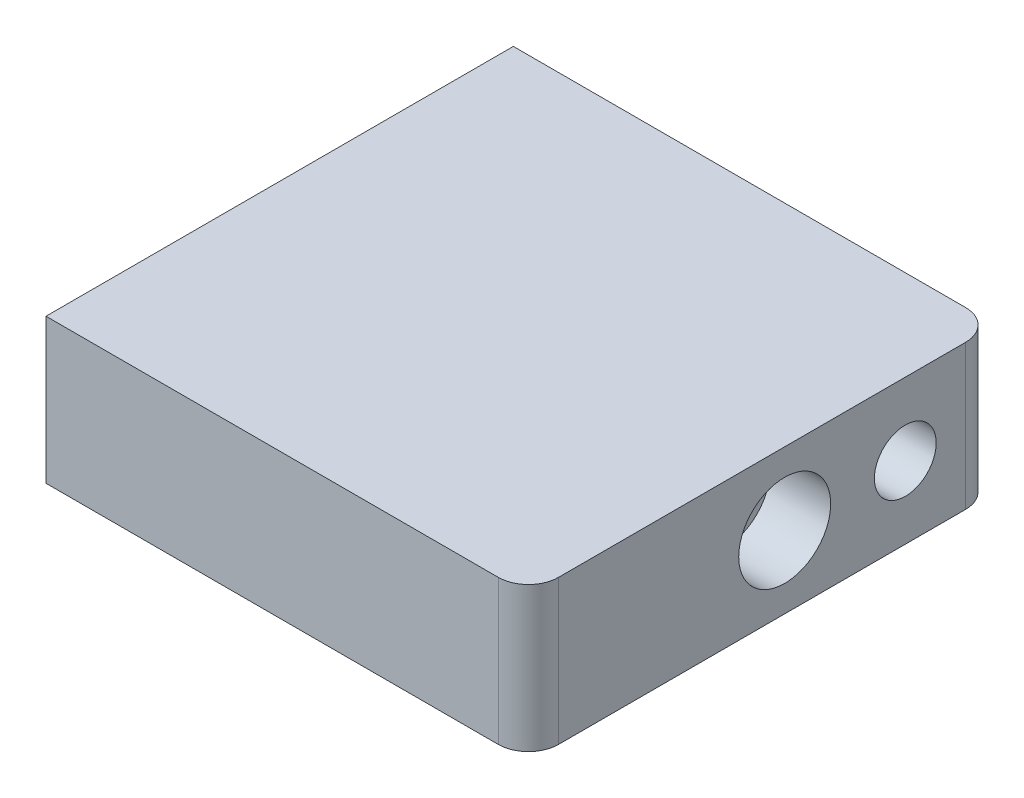
from build123d import *

# Parameters (mm, degrees)
SKETCH1_W           = 80
SKETCH1_H           = 77.5
BOSS_EXTRUDE1_DEPTH = 24
SKETCH2_R           = 5.125
SKETCH2_R_2         = 7.625
CUT_EXTRUDE1_DEPTH  = 10
FILLET1_R           = 5


with BuildPart() as part:
    # Sketch1 → Boss-Extrude1 (new body)
    with BuildSketch(Plane(origin=(0, 0, 0), x_dir=(1, 0, 0), z_dir=(0, 1, 0))):
        with Locations((40, 38.75)):
            Rectangle(SKETCH1_W, SKETCH1_H)
    extrude(amount=BOSS_EXTRUDE1_DEPTH)

    # Sketch2 → Cut-Extrude1 (cut)
    with BuildSketch(Plane(origin=(80, 0, 0), x_dir=(0, 0, -1), z_dir=(1, 0, 0))):
        with Locations((62.5, 12)):
            Circle(SKETCH2_R)
        with Locations((42.5, 12)):
            Circle(SKETCH2_R_2)
    extrude(amount=-CUT_EXTRUDE1_DEPTH, mode=Mode.SUBTRACT)

    # Fillet1
    fillet1_edges = [part.edges().sort_by_distance(p)[0] for p in [
        (80, 12, -77.5),
        (80, 12, 0),
    ]]
    fillet(fillet1_edges, radius=FILLET1_R)


solid = part.part
